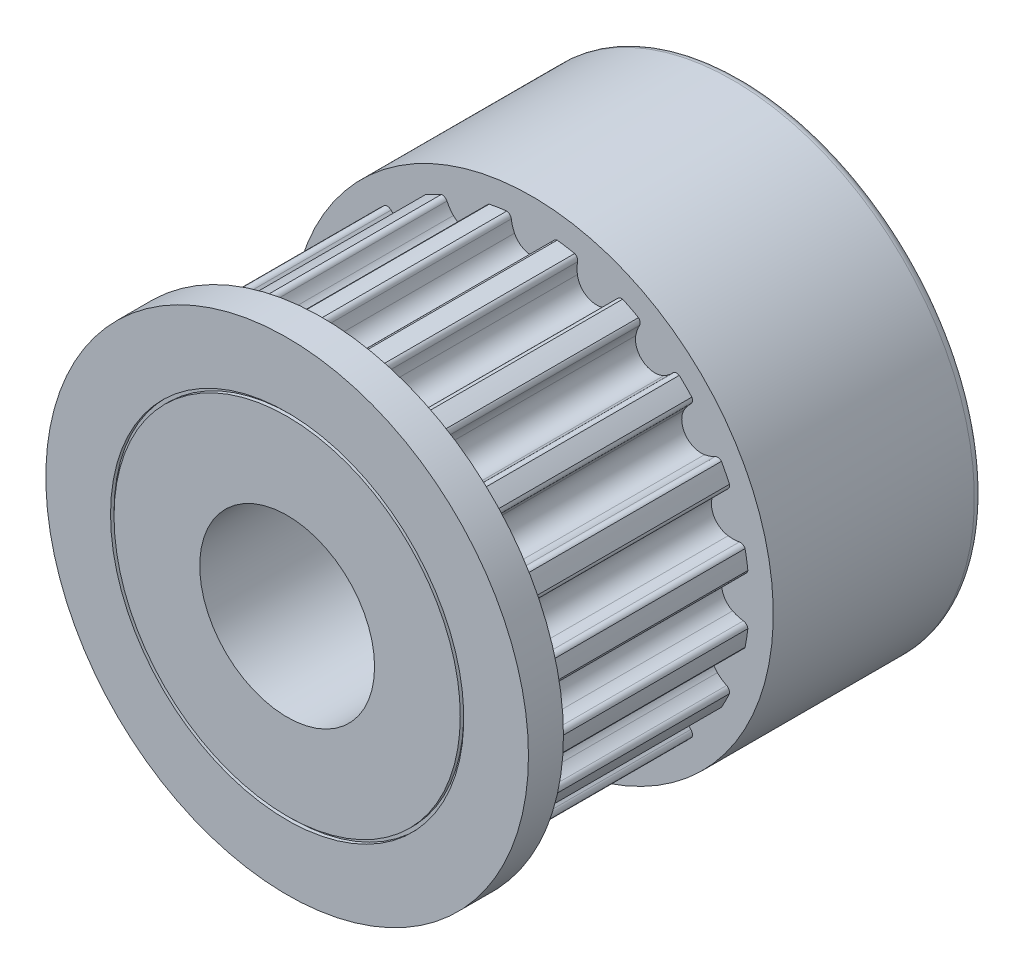
from build123d import *

# Parameters (mm, degrees)
SCHIZZO1_W                   = 6.900000103
SCHIZZO1_H                   = 1
ESTRUSIONE_ESTRUSIONE1_DEPTH = 6
SCHIZZO3_R                   = 6.9
ESTRUSIONE_ESTRUSIONE2_DEPTH = 6
SCHIZZO4_R                   = 5.05
TAGLIO_ESTRUSIONE1_DEPTH     = 0.1
SCHIZZO5_R                   = 4.95
ESTRUSIONE_ESTRUSIONE3_DEPTH = 0.1
FORO1_D                      = 10.1
FORO1_DEPTH                  = 0.1
SCHIZZO8_R                   = 4.95
ESTRUSIONE_ESTRUSIONE4_DEPTH = 0.1
FORO_5_0_5_1_D               = 5
FORO_5_0_5_1_DEPTH           = 13
RACCORDO1_R                  = 0.25


with BuildPart() as part:
    # Schizzo1 → Rivoluzione1 (revolve)
    with BuildSketch(Plane(origin=(0, 0, 0), x_dir=(1, 0, 0), z_dir=(0, 1, 0))):
        with Locations((3.450000051, -17.5)):
            Rectangle(SCHIZZO1_W, SCHIZZO1_H)
    revolve(axis=Axis((0, 0, 17), (0, 0, 1)))

    # Schizzo2 → Estrusione-Estrusione1 (add)
    with BuildSketch(Plane(origin=(0, 0, 17), x_dir=(-1, 0, 0), z_dir=(0, 0, -1))):
        with BuildLine():
            ThreePointArc((5.417673674, -3.045494536), (5.332330694, -3.090379595), (5.237298663, -3.074039287))
            ThreePointArc((5.237298663, -3.074039287), (5.089881745, -3.008769566), (4.933892109, -2.968037297))
            ThreePointArc((4.933892109, -2.968037297), (4.388410235, -3.188366666), (4.347427722, -3.775236276))
            ThreePointArc((4.347427722, -3.775236276), (4.43436986, -3.911004272), (4.541999387, -4.03103664))
            ThreePointArc((4.541999387, -4.03103664), (4.586906456, -4.11636804), (4.570590658, -4.211404283))
            ThreePointArc((4.570590658, -4.211404283), (4.394668645, -4.394668645), (4.211404283, -4.570590658))
            ThreePointArc((4.211404283, -4.570590658), (4.11636804, -4.586906456), (4.03103664, -4.541999387))
            ThreePointArc((4.03103664, -4.541999387), (3.911004272, -4.43436986), (3.775236276, -4.347427722))
            ThreePointArc((3.775236276, -4.347427722), (3.188366666, -4.388410235), (2.968037297, -4.933892109))
            ThreePointArc((2.968037297, -4.933892109), (3.008769566, -5.089881745), (3.074039287, -5.237298663))
            ThreePointArc((3.074039287, -5.237298663), (3.090379595, -5.332330694), (3.045494536, -5.417673674))
            ThreePointArc((3.045494536, -5.417673674), (2.821550956, -5.537605548), (2.592893298, -5.648285523))
            ThreePointArc((2.592893298, -5.648285523), (2.497466601, -5.634434954), (2.430188665, -5.56535694))
            ThreePointArc((2.430188665, -5.56535694), (2.349290452, -5.425903137), (2.247034013, -5.301261631))
            ThreePointArc((2.247034013, -5.301261631), (1.676223553, -5.158885634), (1.298114702, -5.609584206))
            ThreePointArc((1.298114702, -5.609584206), (1.288649943, -5.770526129), (1.305170804, -5.930897402))
            ThreePointArc((1.305170804, -5.930897402), (1.291344848, -6.026327668), (1.222284188, -6.093623418))
            ThreePointArc((1.222284188, -6.093623418), (0.9722402, -6.138483037), (0.720571852, -6.173086846))
            ThreePointArc((0.720571852, -6.173086846), (0.634095731, -6.130425702), (0.591456891, -6.043938581))
            ThreePointArc((0.591456891, -6.043938581), (0.557611714, -5.886311209), (0.498876404, -5.736171116))
            ThreePointArc((0.498876404, -5.736171116), (0, -5.424373363), (-0.498876404, -5.736171116))
            ThreePointArc((-0.498876404, -5.736171116), (-0.557611714, -5.886311209), (-0.591456891, -6.043938581))
            ThreePointArc((-0.591456891, -6.043938581), (-0.634095731, -6.130425702), (-0.720571852, -6.173086846))
            ThreePointArc((-0.720571852, -6.173086846), (-0.9722402, -6.138483037), (-1.222284188, -6.093623418))
            ThreePointArc((-1.222284188, -6.093623418), (-1.291344848, -6.026327668), (-1.305170804, -5.930897402))
            ThreePointArc((-1.305170804, -5.930897402), (-1.288649943, -5.770526129), (-1.298114702, -5.609584206))
            ThreePointArc((-1.298114702, -5.609584206), (-1.676223553, -5.158885634), (-2.247034013, -5.301261631))
            ThreePointArc((-2.247034013, -5.301261631), (-2.349290452, -5.425903137), (-2.430188665, -5.56535694))
            ThreePointArc((-2.430188665, -5.56535694), (-2.497466601, -5.634434954), (-2.592893298, -5.648285523))
            ThreePointArc((-2.592893298, -5.648285523), (-2.821550956, -5.537605548), (-3.045494536, -5.417673674))
            ThreePointArc((-3.045494536, -5.417673674), (-3.090379595, -5.332330694), (-3.074039287, -5.237298663))
            ThreePointArc((-3.074039287, -5.237298663), (-3.008769566, -5.089881745), (-2.968037297, -4.933892109))
            ThreePointArc((-2.968037297, -4.933892109), (-3.188366666, -4.388410235), (-3.775236276, -4.347427722))
            ThreePointArc((-3.775236276, -4.347427722), (-3.911004272, -4.43436986), (-4.03103664, -4.541999387))
            ThreePointArc((-4.03103664, -4.541999387), (-4.11636804, -4.586906456), (-4.211404283, -4.570590658))
            ThreePointArc((-4.211404283, -4.570590658), (-4.394668645, -4.394668645), (-4.570590658, -4.211404283))
            ThreePointArc((-4.570590658, -4.211404283), (-4.586906456, -4.11636804), (-4.541999387, -4.03103664))
            ThreePointArc((-4.541999387, -4.03103664), (-4.43436986, -3.911004272), (-4.347427722, -3.775236276))
            ThreePointArc((-4.347427722, -3.775236276), (-4.388410235, -3.188366666), (-4.933892109, -2.968037297))
            ThreePointArc((-4.933892109, -2.968037297), (-5.089881745, -3.008769566), (-5.237298663, -3.074039287))
            ThreePointArc((-5.237298663, -3.074039287), (-5.332330694, -3.090379595), (-5.417673674, -3.045494536))
            ThreePointArc((-5.417673674, -3.045494536), (-5.537605548, -2.821550956), (-5.648285523, -2.592893298))
            ThreePointArc((-5.648285523, -2.592893298), (-5.634434954, -2.497466601), (-5.56535694, -2.430188665))
            ThreePointArc((-5.56535694, -2.430188665), (-5.425903137, -2.349290452), (-5.301261631, -2.247034013))
            ThreePointArc((-5.301261631, -2.247034013), (-5.158885634, -1.676223553), (-5.609584206, -1.298114702))
            ThreePointArc((-5.609584206, -1.298114702), (-5.770526129, -1.288649943), (-5.930897402, -1.305170804))
            ThreePointArc((-5.930897402, -1.305170804), (-6.026327668, -1.291344848), (-6.093623418, -1.222284188))
            ThreePointArc((-6.093623418, -1.222284188), (-6.138483037, -0.9722402), (-6.173086846, -0.720571852))
            ThreePointArc((-6.173086846, -0.720571852), (-6.130425702, -0.634095731), (-6.043938581, -0.591456891))
            ThreePointArc((-6.043938581, -0.591456891), (-5.886311209, -0.557611714), (-5.736171116, -0.498876404))
            ThreePointArc((-5.736171116, -0.498876404), (-5.424373363, 0), (-5.736171116, 0.498876404))
            ThreePointArc((-5.736171116, 0.498876404), (-5.886311209, 0.557611714), (-6.043938581, 0.591456891))
            ThreePointArc((-6.043938581, 0.591456891), (-6.130425702, 0.634095731), (-6.173086846, 0.720571852))
            ThreePointArc((-6.173086846, 0.720571852), (-6.138483037, 0.9722402), (-6.093623418, 1.222284188))
            ThreePointArc((-6.093623418, 1.222284188), (-6.026327668, 1.291344848), (-5.930897402, 1.305170804))
            ThreePointArc((-5.930897402, 1.305170804), (-5.770526129, 1.288649943), (-5.609584206, 1.298114702))
            ThreePointArc((-5.609584206, 1.298114702), (-5.158885634, 1.676223553), (-5.301261631, 2.247034013))
            ThreePointArc((-5.301261631, 2.247034013), (-5.425903137, 2.349290452), (-5.56535694, 2.430188665))
            ThreePointArc((-5.56535694, 2.430188665), (-5.634434954, 2.497466601), (-5.648285523, 2.592893298))
            ThreePointArc((-5.648285523, 2.592893298), (-5.537605548, 2.821550956), (-5.417673674, 3.045494536))
            ThreePointArc((-5.417673674, 3.045494536), (-5.332330694, 3.090379595), (-5.237298663, 3.074039287))
            ThreePointArc((-5.237298663, 3.074039287), (-5.089881745, 3.008769566), (-4.933892109, 2.968037297))
            ThreePointArc((-4.933892109, 2.968037297), (-4.388410235, 3.188366666), (-4.347427722, 3.775236276))
            ThreePointArc((-4.347427722, 3.775236276), (-4.43436986, 3.911004272), (-4.541999387, 4.03103664))
            ThreePointArc((-4.541999387, 4.03103664), (-4.586906456, 4.11636804), (-4.570590658, 4.211404283))
            ThreePointArc((-4.570590658, 4.211404283), (-4.394668645, 4.394668645), (-4.211404283, 4.570590658))
            ThreePointArc((-4.211404283, 4.570590658), (-4.11636804, 4.586906456), (-4.03103664, 4.541999387))
            ThreePointArc((-4.03103664, 4.541999387), (-3.911004272, 4.43436986), (-3.775236276, 4.347427722))
            ThreePointArc((-3.775236276, 4.347427722), (-3.188366666, 4.388410235), (-2.968037297, 4.933892109))
            ThreePointArc((-2.968037297, 4.933892109), (-3.008769566, 5.089881745), (-3.074039287, 5.237298663))
            ThreePointArc((-3.074039287, 5.237298663), (-3.090379595, 5.332330694), (-3.045494536, 5.417673674))
            ThreePointArc((-3.045494536, 5.417673674), (-2.821550956, 5.537605548), (-2.592893298, 5.648285523))
            ThreePointArc((-2.592893298, 5.648285523), (-2.497466601, 5.634434954), (-2.430188665, 5.56535694))
            ThreePointArc((-2.430188665, 5.56535694), (-2.349290452, 5.425903137), (-2.247034013, 5.301261631))
            ThreePointArc((-2.247034013, 5.301261631), (-1.676223553, 5.158885634), (-1.298114702, 5.609584206))
            ThreePointArc((-1.298114702, 5.609584206), (-1.288649943, 5.770526129), (-1.305170804, 5.930897402))
            ThreePointArc((-1.305170804, 5.930897402), (-1.291344848, 6.026327668), (-1.222284188, 6.093623418))
            ThreePointArc((-1.222284188, 6.093623418), (-0.9722402, 6.138483037), (-0.720571852, 6.173086846))
            ThreePointArc((-0.720571852, 6.173086846), (-0.634095731, 6.130425702), (-0.591456891, 6.043938581))
            ThreePointArc((-0.591456891, 6.043938581), (-0.557611714, 5.886311209), (-0.498876404, 5.736171116))
            ThreePointArc((-0.498876404, 5.736171116), (0, 5.424373363), (0.498876404, 5.736171116))
            ThreePointArc((0.498876404, 5.736171116), (0.557611714, 5.886311209), (0.591456891, 6.043938581))
            ThreePointArc((0.591456891, 6.043938581), (0.634095731, 6.130425702), (0.720571852, 6.173086846))
            ThreePointArc((0.720571852, 6.173086846), (0.9722402, 6.138483037), (1.222284188, 6.093623418))
            ThreePointArc((1.222284188, 6.093623418), (1.291344848, 6.026327668), (1.305170804, 5.930897402))
            ThreePointArc((1.305170804, 5.930897402), (1.288649943, 5.770526129), (1.298114702, 5.609584206))
            ThreePointArc((1.298114702, 5.609584206), (1.676223553, 5.158885634), (2.247034013, 5.301261631))
            ThreePointArc((2.247034013, 5.301261631), (2.349290452, 5.425903137), (2.430188665, 5.56535694))
            ThreePointArc((2.430188665, 5.56535694), (2.497466601, 5.634434954), (2.592893298, 5.648285523))
            ThreePointArc((2.592893298, 5.648285523), (2.821550956, 5.537605548), (3.045494536, 5.417673674))
            ThreePointArc((3.045494536, 5.417673674), (3.090379595, 5.332330694), (3.074039287, 5.237298663))
            ThreePointArc((3.074039287, 5.237298663), (3.008769566, 5.089881745), (2.968037297, 4.933892109))
            ThreePointArc((2.968037297, 4.933892109), (3.188366666, 4.388410235), (3.775236276, 4.347427722))
            ThreePointArc((3.775236276, 4.347427722), (3.911004272, 4.43436986), (4.03103664, 4.541999387))
            ThreePointArc((4.03103664, 4.541999387), (4.11636804, 4.586906456), (4.211404283, 4.570590658))
            ThreePointArc((4.211404283, 4.570590658), (4.394668645, 4.394668645), (4.570590658, 4.211404283))
            ThreePointArc((4.570590658, 4.211404283), (4.586906456, 4.11636804), (4.541999387, 4.03103664))
            ThreePointArc((4.541999387, 4.03103664), (4.43436986, 3.911004272), (4.347427722, 3.775236276))
            ThreePointArc((4.347427722, 3.775236276), (4.388410235, 3.188366666), (4.933892109, 2.968037297))
            ThreePointArc((4.933892109, 2.968037297), (5.089881745, 3.008769566), (5.237298663, 3.074039287))
            ThreePointArc((5.237298663, 3.074039287), (5.332330694, 3.090379595), (5.417673674, 3.045494536))
            ThreePointArc((5.417673674, 3.045494536), (5.537605548, 2.821550956), (5.648285523, 2.592893298))
            ThreePointArc((5.648285523, 2.592893298), (5.634434954, 2.497466601), (5.56535694, 2.430188665))
            ThreePointArc((5.56535694, 2.430188665), (5.425903137, 2.349290452), (5.301261631, 2.247034013))
            ThreePointArc((5.301261631, 2.247034013), (5.158885634, 1.676223553), (5.609584206, 1.298114702))
            ThreePointArc((5.609584206, 1.298114702), (5.770526129, 1.288649943), (5.930897402, 1.305170804))
            ThreePointArc((5.930897402, 1.305170804), (6.026327668, 1.291344848), (6.093623418, 1.222284188))
            ThreePointArc((6.093623418, 1.222284188), (6.138483037, 0.9722402), (6.173086846, 0.720571852))
            ThreePointArc((6.173086846, 0.720571852), (6.130425702, 0.634095731), (6.043938581, 0.591456891))
            ThreePointArc((6.043938581, 0.591456891), (5.886311209, 0.557611714), (5.736171116, 0.498876404))
            ThreePointArc((5.736171116, 0.498876404), (5.424373363, 0), (5.736171116, -0.498876404))
            ThreePointArc((5.736171116, -0.498876404), (5.886311209, -0.557611714), (6.043938581, -0.591456891))
            ThreePointArc((6.043938581, -0.591456891), (6.130425702, -0.634095731), (6.173086846, -0.720571852))
            ThreePointArc((6.173086846, -0.720571852), (6.138483037, -0.9722402), (6.093623418, -1.222284188))
            ThreePointArc((6.093623418, -1.222284188), (6.026327668, -1.291344848), (5.930897402, -1.305170804))
            ThreePointArc((5.930897402, -1.305170804), (5.770526129, -1.288649943), (5.609584206, -1.298114702))
            ThreePointArc((5.609584206, -1.298114702), (5.158885634, -1.676223553), (5.301261631, -2.247034013))
            ThreePointArc((5.301261631, -2.247034013), (5.425903137, -2.349290452), (5.56535694, -2.430188665))
            ThreePointArc((5.56535694, -2.430188665), (5.634434954, -2.497466601), (5.648285523, -2.592893298))
            ThreePointArc((5.648285523, -2.592893298), (5.537605548, -2.821550956), (5.417673674, -3.045494536))
        make_face()
    extrude(amount=ESTRUSIONE_ESTRUSIONE1_DEPTH)

    # Schizzo3 → Estrusione-Estrusione2 (add)
    with BuildSketch(Plane.XY.offset(11)):
        Circle(SCHIZZO3_R)
    extrude(amount=-ESTRUSIONE_ESTRUSIONE2_DEPTH)

    # Schizzo4 → Taglio-Estrusione1 (cut)
    with BuildSketch(Plane.XY.offset(18)):
        Circle(SCHIZZO4_R)
    extrude(amount=-TAGLIO_ESTRUSIONE1_DEPTH, mode=Mode.SUBTRACT)

    # Schizzo5 → Estrusione-Estrusione3 (add)
    with BuildSketch(Plane.XY.offset(17.9)):
        Circle(SCHIZZO5_R)
    extrude(amount=ESTRUSIONE_ESTRUSIONE3_DEPTH)

    # Foro1
    with Locations(Plane(origin=(0, 0, 5), x_dir=(-1, 0, 0), z_dir=(0, 0, -1))):
        with Locations((0, 0)):
            Hole(FORO1_D / 2, depth=FORO1_DEPTH)

    # Schizzo8 → Estrusione-Estrusione4 (add)
    with BuildSketch(Plane(origin=(0, 0, 5.1), x_dir=(-1, 0, 0), z_dir=(0, 0, -1))):
        Circle(SCHIZZO8_R)
    extrude(amount=ESTRUSIONE_ESTRUSIONE4_DEPTH)

    # Foro Ø5.0 (5)-1
    with Locations(Plane.XY.offset(18)):
        with Locations((0, 0)):
            Hole(FORO_5_0_5_1_D / 2, depth=FORO_5_0_5_1_DEPTH)

    # Raccordo1
    raccordo1_edges = [part.edges().sort_by_distance(p)[0] for p in [
        (-6.9, 0, 5),
    ]]
    fillet(raccordo1_edges, radius=RACCORDO1_R)


solid = part.part
